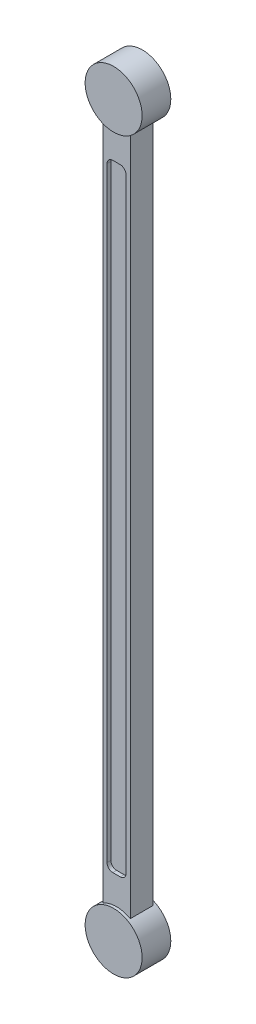
from build123d import *

# Parameters (mm, degrees)
EXTRUDE1_DEPTH      = 19.05
EXTRUDE1_DEPTH_BACK = 19
CUT_EXTRUDE1_DEPTH  = 6.35
CUT_EXTRUDE2_DEPTH  = 6.35
SKETCH6_R           = 47.657715
SKETCH6_R_2         = 47.657166
EXTRUDE2_DEPTH      = 4.826
EXTRUDE2_DEPTH_BACK = 43.18


with BuildPart() as part:
    # Sketch3 → Extrude1 (new body, two sides)
    with BuildSketch(Plane.XY) as extrude1_sk:
        with BuildLine():
            Line((23, 1178.259012), (23, 41.73971))
            ThreePointArc((23, 41.73971), (0, -47.657144), (-23, 41.73971))
            Line((-23, 41.73971), (-23, 1178.259012))
            ThreePointArc((-23, 1178.259012), (0, 1267.657089), (23, 1178.259012))
        make_face()
    extrude(amount=EXTRUDE1_DEPTH)
    extrude(extrude1_sk.sketch, amount=-EXTRUDE1_DEPTH_BACK)

    # Sketch4 → Cut-Extrude1 (cut)
    with BuildSketch(Plane.XY.offset(19.05)):
        with BuildLine():
            Line((15.888, 1116.347374), (15.888, 103.651374))
            ThreePointArc((15.888, 103.651374), (13.060995, 96.826379), (6.236, 93.999374))
            Line((6.236, 93.999374), (-6.236, 93.999374))
            ThreePointArc((-6.236, 93.999374), (-13.060995, 96.826379), (-15.888, 103.651374))
            Line((-15.888, 103.651374), (-15.888, 1116.347374))
            ThreePointArc((-15.888, 1116.347374), (-13.060995, 1123.172368), (-6.236, 1125.999374))
            Line((-6.236, 1125.999374), (6.236, 1125.999374))
            ThreePointArc((6.236, 1125.999374), (13.060995, 1123.172368), (15.888, 1116.347374))
        make_face()
    extrude(amount=-CUT_EXTRUDE1_DEPTH, mode=Mode.SUBTRACT)

    # Sketch5 → Cut-Extrude2 (cut)
    with BuildSketch(Plane(origin=(0, 0, -19), x_dir=(-1, 0, 0), z_dir=(0, 0, -1))):
        with BuildLine():
            Line((-15.888, 1116.347374), (-15.888, 103.651374))
            ThreePointArc((-15.888, 103.651374), (-13.060995, 96.826379), (-6.236, 93.999374))
            Line((-6.236, 93.999374), (6.236, 93.999374))
            ThreePointArc((6.236, 93.999374), (13.060995, 96.826379), (15.888, 103.651374))
            Line((15.888, 103.651374), (15.888, 1116.347374))
            ThreePointArc((15.888, 1116.347374), (13.060995, 1123.172368), (6.236, 1125.999374))
            Line((6.236, 1125.999374), (-6.236, 1125.999374))
            ThreePointArc((-6.236, 1125.999374), (-13.060995, 1123.172368), (-15.888, 1116.347374))
        make_face()
    extrude(amount=-CUT_EXTRUDE2_DEPTH, mode=Mode.SUBTRACT)

    # Sketch6 → Extrude2 (add, two sides)
    with BuildSketch(Plane.XY.offset(19.05)) as extrude2_sk:
        with Locations((0, 1219.999374)):
            Circle(SKETCH6_R)
        Circle(SKETCH6_R_2)
    extrude(amount=EXTRUDE2_DEPTH)
    extrude(extrude2_sk.sketch, amount=-EXTRUDE2_DEPTH_BACK)


solid = part.part
